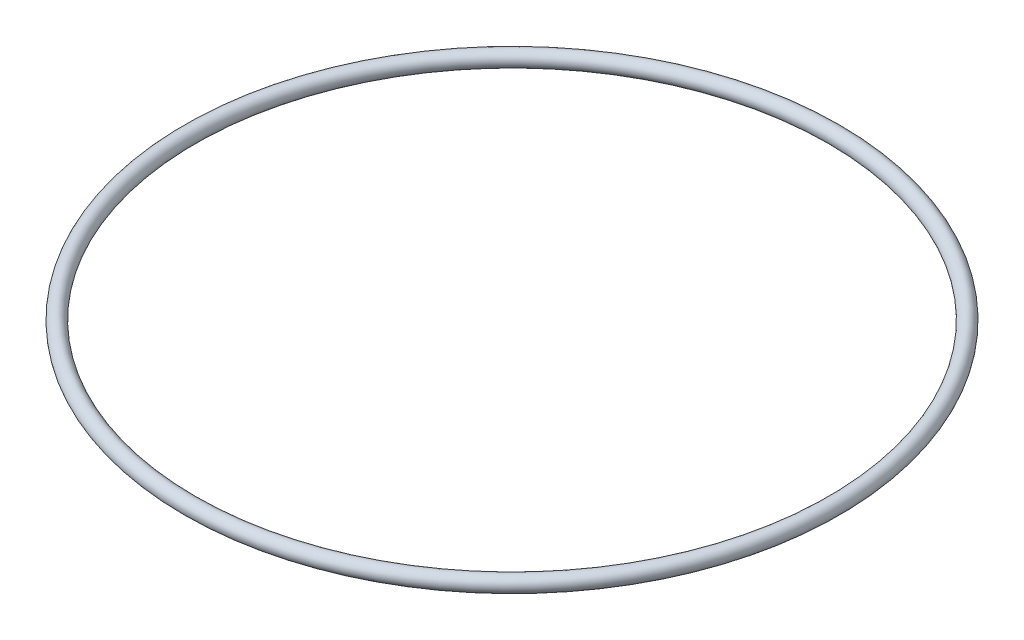
from build123d import *

# Parameters (mm, degrees)
SKETCH1_R = 0.5


with BuildPart() as part:
    # Sketch1 → Revolve1 (revolve)
    with BuildSketch(Plane(origin=(0, 0, 0), x_dir=(0, 0, -1), z_dir=(1, 0, 0))):
        with Locations((21, 0)):
            Circle(SKETCH1_R)
    revolve(axis=Axis((0, 1.457950572, 0), (0, -1, 0)))


solid = part.part
